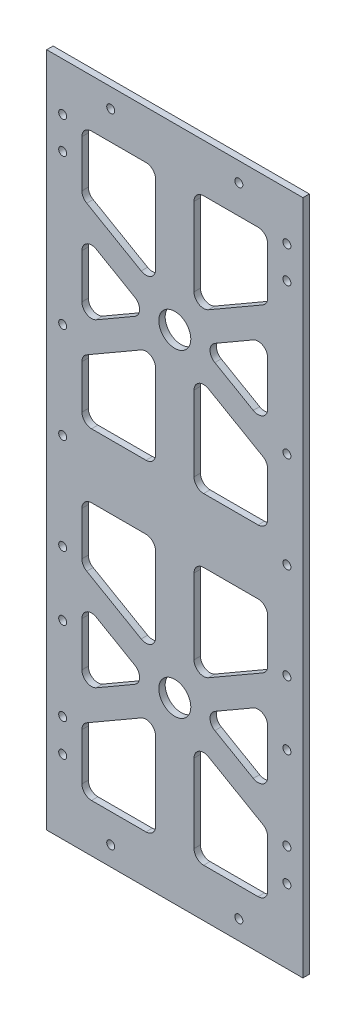
from build123d import *

# Parameters (mm, degrees)
SKETCH1_W                 = 88
SKETCH1_H                 = 211
BOSS_EXTRUDE1_DEPTH       = 2
CUT_EXTRUDE2_DEPTH        = 2
SKETCH4_R                 = 5
CUT_EXTRUDE3_DEPTH        = 3
FILLET2_R                 = 3
SKETCH23_W                = 2
SKETCH23_H                = 211
SKETCH23_W_2              = 2.150374681
CUT_EXTRUDE5_DEPTH        = 10
SKETCH29_W                = 5.911493913
SKETCH29_H                = 211
SKETCH29_W_2              = 4.036537762
CUT_EXTRUDE10_DEPTH       = 2
M3X0_5_TAPPED_HOLE1_D     = 2.5
M3X0_5_TAPPED_HOLE1_DEPTH = 10
M3X0_5_TAPPED_HOLE1_TIP   = 0.751075774


with BuildPart() as part:
    # Sketch1 → Boss-Extrude1 (new body)
    with BuildSketch(Plane.XY):
        with Locations((44, 105.5)):
            Rectangle(SKETCH1_W, SKETCH1_H)
    extrude(amount=BOSS_EXTRUDE1_DEPTH)

    # Sketch3 → Cut-Extrude2 (cut)
    with BuildSketch(Plane.XY.offset(2)):
        Polygon((73, 133.88804004), (50, 147.167096231), (50, 115.5), (73, 115.5), align=None)
        Polygon((38, 115.5), (38, 147.167096231), (15, 133.88804004), (15, 115.5), align=None)
        Polygon((15, 143.125644347), (36, 155.25), (15, 167.374355653), align=None)
        Polygon((73, 143.125644347), (73, 167.374355653), (52, 155.25), align=None)
        Polygon((73, 196), (50, 196), (50, 163.332903769), (73, 176.61195996), align=None)
        Polygon((38, 163.332903769), (38, 196), (15, 196), (15, 176.61195996), align=None)
    cut_extrude2 = extrude(amount=-CUT_EXTRUDE2_DEPTH, mode=Mode.SUBTRACT)

    # Sketch4 → Cut-Extrude3 (cut, through all)
    with BuildSketch(Plane.XY.offset(2)):
        with Locations((44, 155.25)):
            Circle(SKETCH4_R)
    cut_extrude3 = extrude(amount=-CUT_EXTRUDE3_DEPTH, mode=Mode.SUBTRACT)

    # Mirror2: Cut-Extrude2, Cut-Extrude3 across plane
    add(cut_extrude2.mirror(Plane.ZX.offset(105.5)), mode=Mode.SUBTRACT)
    add(cut_extrude3.mirror(Plane.ZX.offset(105.5)), mode=Mode.SUBTRACT)

    # Fillet2
    fillet2_edges = [part.edges().sort_by_distance(p)[0] for p in [
        (36, 55.75, 1),
        (15, 43.625644347, 1),
        (15, 67.874355653, 1),
        (38, 95.5, 1),
        (38, 63.832903769, 1),
        (15, 77.11195996, 1),
        (15, 95.5, 1),
        (73, 15, 1),
        (50, 15, 1),
        (50, 47.667096231, 1),
        (73, 34.38804004, 1),
        (73, 43.625644347, 1),
        (52, 55.75, 1),
        (73, 67.874355653, 1),
        (15, 15, 1),
        (15, 34.38804004, 1),
        (38, 47.667096231, 1),
        (38, 15, 1),
        (73, 77.11195996, 1),
        (50, 63.832903769, 1),
        (50, 95.5, 1),
        (73, 95.5, 1),
        (15, 167.374355653, 1),
        (36, 155.25, 1),
        (15, 143.125644347, 1),
        (38, 147.167096231, 1),
        (38, 115.5, 1),
        (15, 115.5, 1),
        (15, 133.88804004, 1),
        (50, 196, 1),
        (73, 196, 1),
        (73, 176.61195996, 1),
        (50, 163.332903769, 1),
        (52, 155.25, 1),
        (73, 167.374355653, 1),
        (73, 143.125644347, 1),
        (15, 176.61195996, 1),
        (15, 196, 1),
        (38, 196, 1),
        (38, 163.332903769, 1),
        (50, 147.167096231, 1),
        (73, 133.88804004, 1),
        (73, 115.5, 1),
        (50, 115.5, 1),
    ]]
    fillet(fillet2_edges, radius=FILLET2_R)

    # Sketch23 → Cut-Extrude5 (cut)
    with BuildSketch(Plane.XY.offset(2)):
        with Locations((87, 105.5)):
            Rectangle(SKETCH23_W, SKETCH23_H)
        with Locations((1.075187341, 105.5)):
            Rectangle(SKETCH23_W_2, SKETCH23_H)
    extrude(amount=-CUT_EXTRUDE5_DEPTH, mode=Mode.SUBTRACT)

    # Sketch29 → Cut-Extrude10 (cut)
    with BuildSketch(Plane(origin=(0, 0, 0), x_dir=(-1, 0, 0), z_dir=(0, 0, -1))):
        with Locations((-1.044253043, 105.5)):
            Rectangle(SKETCH29_W, SKETCH29_H)
        with Locations((-86.018268881, 105.5)):
            Rectangle(SKETCH29_W_2, SKETCH29_H)
    extrude(amount=-CUT_EXTRUDE10_DEPTH, mode=Mode.SUBTRACT)

    # M3x0.5 Tapped Hole1
    with Locations(Plane.XY.offset(2)):
        with Locations((9, 186), (9, 139.2), (9, 109.2), (9, 79.2), (9, 59.2), (9, 33.2), (79, 186), (79, 139.2), (79, 109.2), (79, 79.2), (79, 59.2), (79, 33.2), (24, 6), (64, 6), (24, 205), (64, 205), (9, 196), (79, 196), (9, 23), (79, 23)):
            Hole(M3X0_5_TAPPED_HOLE1_D / 2, depth=M3X0_5_TAPPED_HOLE1_DEPTH)
            with Locations((0, 0, -(M3X0_5_TAPPED_HOLE1_DEPTH + M3X0_5_TAPPED_HOLE1_TIP / 2))):  # 118° drill point
                Cone(0, M3X0_5_TAPPED_HOLE1_D / 2, M3X0_5_TAPPED_HOLE1_TIP, mode=Mode.SUBTRACT)


solid = part.part
